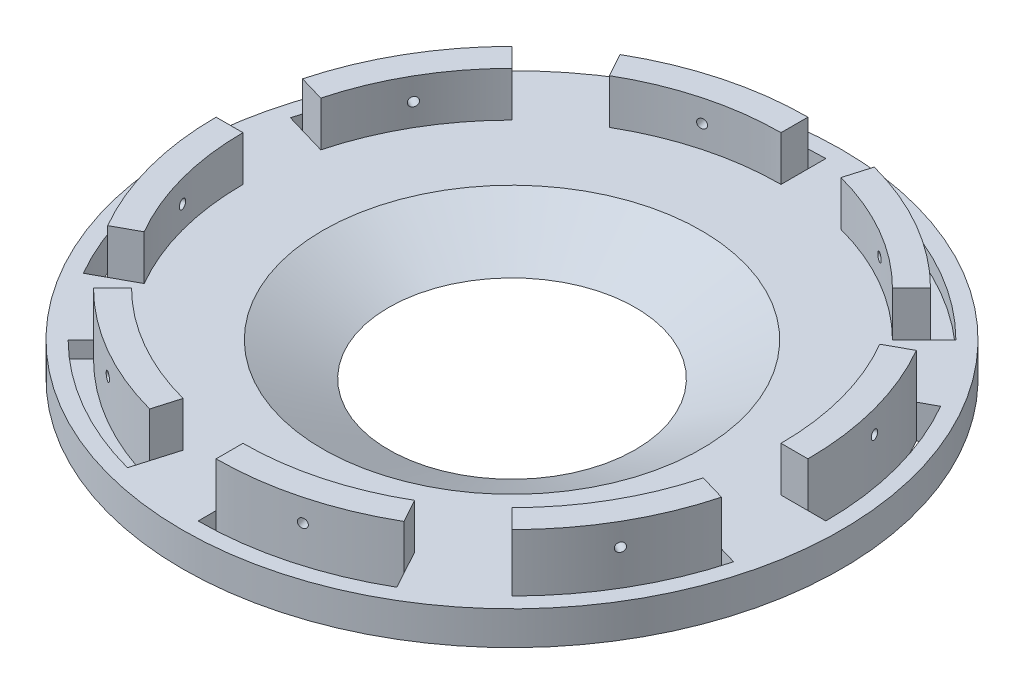
from build123d import *

# Parameters (mm, degrees)
BASE_DEPTH                 = 4.7625
BASE_DEPTH_BACK            = 4.7625
SKETCH1_R                  = 93.345
BOTTOM_SUPPORT_HOLES_DEPTH = 133.352951138
BOTTOM_START               = 12.7
BOTTOM_SUPPORT_GUIDE_DEPTH = 12.7
SKETCH6_R                  = 1.27
BOTTOM_BOLT_HOLE_DEPTH     = 12.7
TOP_SUPPORT_HOLES_DEPTH    = 4.7625
TOP_START                  = 12.7
TOP_SUPPORT_GUIDE_DEPTH    = 12.7
SKETCH12_R                 = 1.27
TOP_BOLT_HOLE_DEPTH        = 12.7
BOTTOM_PATTERN_COUNT       = 4
CIRPATTERN3_COUNT          = 4
SKETCH13_R                 = 34.925
CUT_EXTRUDE5_DEPTH         = 12.7


with BuildPart() as part:
    # Sketch1 → Base (new, two sides: drawn at the far end of the back side and taken through both)
    with BuildSketch(Plane(origin=(0, 0, 0), x_dir=(1, 0, 0), z_dir=(0, 1, 0)).offset(-BASE_DEPTH_BACK)):
        Circle(SKETCH1_R)
    extrude(amount=BASE_DEPTH + BASE_DEPTH_BACK)

    # Sketch2 → Bottom support holes (cut, through all)
    with BuildSketch(Plane(origin=(0, 4.7625, 0), x_dir=(1, 0, 0), z_dir=(0, 1, 0))):
        with BuildLine():
            Line((0, 88.9), (0, 83.82))
            ThreePointArc((0, 83.82), (-21.72026739, 80.956916842), (-41.956713931, 72.563258996))
            Line((-41.956713931, 72.563258996), (-44.39288973, 77.022602796))
            ThreePointArc((-44.39288973, 77.022602796), (-22.977169228, 85.879332172), (0, 88.9))
        make_face()
    bottom_support_holes = extrude(amount=-BOTTOM_SUPPORT_HOLES_DEPTH, mode=Mode.SUBTRACT)

    # Sketch3 → Bottom support guide (add)
    with BuildSketch(Plane(origin=(0, 4.7625, 0), x_dir=(1, 0, 0), z_dir=(0, 1, 0)).offset(BOTTOM_START)):
        with BuildLine():
            Line((0, 83.82), (0, 76.2))
            ThreePointArc((0, 76.2), (-19.834896001, 73.573207764), (-38.302281481, 65.8739344))
            Line((-38.302281481, 65.8739344), (-41.956713931, 72.563258996))
            ThreePointArc((-41.956713931, 72.563258996), (-21.72026739, 80.956916842), (0, 83.82))
        make_face()
    bottom_support_guide = extrude(amount=-BOTTOM_SUPPORT_GUIDE_DEPTH)

    # Sketch6 → Bottom bolt hole (cut, symmetric)
    with BuildSketch(Plane(origin=(-20.978356966, 0, -78.191629498), x_dir=(-0.9658424820058785, 0, 0.2591298901183038), z_dir=(-0.2591298901183038, 0, -0.9658424820058785))):
        with Locations((-0.00326739, 11.1125)):
            Circle(SKETCH6_R)
    bottom_bolt_hole = extrude(amount=BOTTOM_BOLT_HOLE_DEPTH, both=True, mode=Mode.SUBTRACT)

    # Sketch8 → Top support holes (cut)
    with BuildSketch(Plane(origin=(-31.122978549, 4.7625, 77.296707326), x_dir=(1, 0, 0), z_dir=(0, 1, 0))):
        with BuildLine():
            Line((-31.738814298, 140.158500173), (-28.14671185, 136.566397725))
            ThreePointArc((-28.14671185, 136.566397725), (-41.480754694, 119.183343848), (-49.854870889, 98.93880289))
            Line((-49.854870889, 98.93880289), (-54.730739557, 100.369398703))
            ThreePointArc((-54.730739557, 100.369398703), (-45.850191767, 121.775253295), (-31.738814298, 140.158500173))
        make_face()
    top_support_holes = extrude(amount=-TOP_SUPPORT_HOLES_DEPTH, mode=Mode.SUBTRACT)

    # Sketch10 → Top support guide (add)
    with BuildSketch(Plane(origin=(-31.122978549, 4.7625, 77.296707326), x_dir=(1, 0, 0), z_dir=(0, 1, 0)).offset(TOP_START)):
        with BuildLine():
            Line((-28.14671185, 136.566397725), (-22.758558177, 131.178244052))
            ThreePointArc((-22.758558177, 131.178244052), (-34.92652504, 115.295431983), (-42.540730139, 96.792810073))
            Line((-42.540730139, 96.792810073), (-49.854870889, 98.93880289))
            ThreePointArc((-49.854870889, 98.93880289), (-41.480754694, 119.183343848), (-28.14671185, 136.566397725))
        make_face()
    top_support_guide = extrude(amount=-TOP_SUPPORT_GUIDE_DEPTH)

    # Sketch12 → Top bolt hole (cut, symmetric)
    with BuildSketch(Plane(origin=(-70.123769919, 0, -40.455892982), x_dir=(-0.4997212660736201, -5.817861610189737e-15, 0.8661862710951832), z_dir=(-0.8661862710951832, 1.404556040332972e-14, -0.4997212660736201))):
        with Locations((-0.00326739, 11.1125)):
            Circle(SKETCH12_R)
    top_bolt_hole = extrude(amount=TOP_BOLT_HOLE_DEPTH, both=True, mode=Mode.SUBTRACT)

    # Bottom pattern: Bottom support holes, Bottom support guide, Bottom bolt hole ×4 about axis
    bottom_pattern_axis = Axis((0, 4.7625, 0), (0, 1, 0))
    add([bottom_support_holes.rotate(bottom_pattern_axis, i * 360 / BOTTOM_PATTERN_COUNT) for i in range(1, BOTTOM_PATTERN_COUNT)], mode=Mode.SUBTRACT)
    add([bottom_support_guide.rotate(bottom_pattern_axis, i * 360 / BOTTOM_PATTERN_COUNT) for i in range(1, BOTTOM_PATTERN_COUNT)])
    add([bottom_bolt_hole.rotate(bottom_pattern_axis, i * 360 / BOTTOM_PATTERN_COUNT) for i in range(1, BOTTOM_PATTERN_COUNT)], mode=Mode.SUBTRACT)

    # CirPattern3: Top support holes, Top support guide, Top bolt hole ×4 about axis
    cirpattern3_axis = Axis((0, 4.7625, 0), (0, 1, 0))
    add([top_support_holes.rotate(cirpattern3_axis, i * 360 / CIRPATTERN3_COUNT) for i in range(1, CIRPATTERN3_COUNT)], mode=Mode.SUBTRACT)
    add([top_support_guide.rotate(cirpattern3_axis, i * 360 / CIRPATTERN3_COUNT) for i in range(1, CIRPATTERN3_COUNT)])
    add([top_bolt_hole.rotate(cirpattern3_axis, i * 360 / CIRPATTERN3_COUNT) for i in range(1, CIRPATTERN3_COUNT)], mode=Mode.SUBTRACT)

    # Sketch13 → Cut-Extrude5 (cut)
    with BuildSketch(Plane(origin=(0, 4.7625, 0), x_dir=(1, 0, 0), z_dir=(0, 1, 0))):
        Circle(SKETCH13_R)
    extrude(amount=-CUT_EXTRUDE5_DEPTH, mode=Mode.SUBTRACT)

    # Sketch14 → Cut-Revolve1 (revolve, cut)
    with BuildSketch(Plane.XY):
        Polygon((34.925, 4.7625), (34.925, -4.7625), (53.618865065, 4.7625), align=None)
    revolve(axis=Axis((0, 25.4, 0), (0, -1, 0)), mode=Mode.SUBTRACT)


solid = part.part
